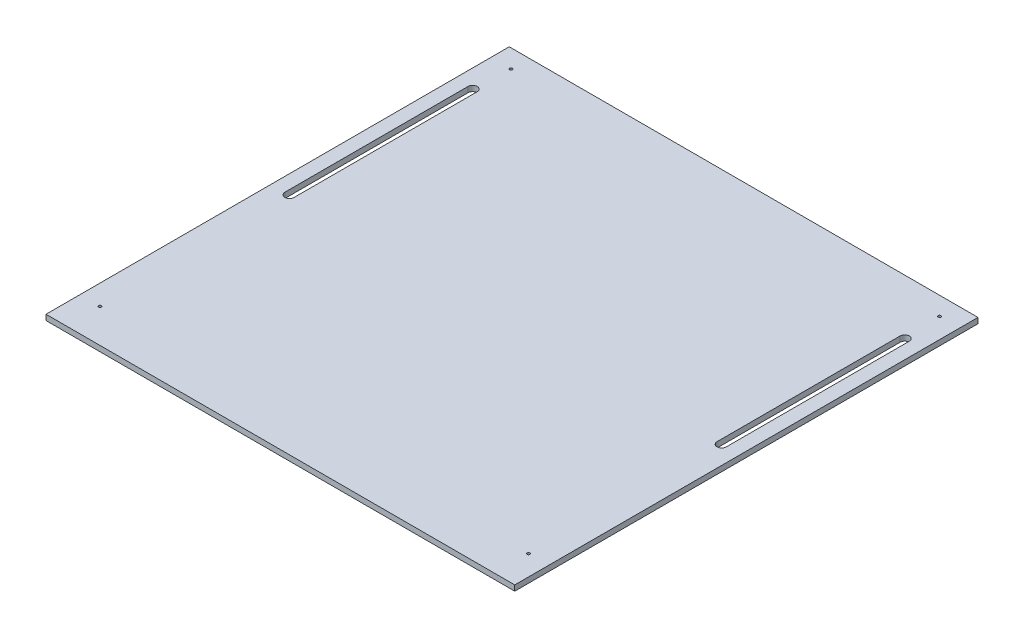
from build123d import *

# Parameters (mm, degrees)
SKETCH1_W           = 500
SKETCH1_H           = 500
SKETCH1_R           = 1.525
SKETCH1_R_2         = 1.5
BOSS_EXTRUDE1_DEPTH = 6
BOSS_EXTRUDE2_DEPTH = 6
CUT_EXTRUDE1_DEPTH  = 7


with BuildPart() as part:
    # Sketch1 → Boss-Extrude1 (new body)
    with BuildSketch(Plane(origin=(0, 0, 0), x_dir=(1, 0, 0), z_dir=(0, 1, 0))):
        with Locations((250, -250)):
            Rectangle(SKETCH1_W, SKETCH1_H)
        with Locations((484, -20)):
            Circle(SKETCH1_R, mode=Mode.SUBTRACT)
        with Locations((16, -20)):
            Circle(SKETCH1_R_2, mode=Mode.SUBTRACT)
        with Locations((484, -469)):
            Circle(SKETCH1_R_2, mode=Mode.SUBTRACT)
        with Locations((16, -469)):
            Circle(SKETCH1_R_2, mode=Mode.SUBTRACT)
    extrude(amount=BOSS_EXTRUDE1_DEPTH)

    # Sketch2 → Boss-Extrude2 (add)
    with BuildSketch(Plane.XZ):
        Polygon((-6, 506), (-6, 0), (0, 0), (0, 500), (500, 500), (500, 0), (506, 0), (506, 506), align=None)
    extrude(amount=-BOSS_EXTRUDE2_DEPTH)

    # Sketch3 → Cut-Extrude1 (cut, through all)
    with BuildSketch(Plane.XZ):
        with BuildLine():
            Line((9, 60), (9, 260))
            ThreePointArc((9, 260), (14, 265), (19, 260))
            Line((19, 260), (19, 60))
            ThreePointArc((19, 60), (14, 55), (9, 60))
        make_face()
        with BuildLine():
            Line((491, 60), (491, 260))
            ThreePointArc((491, 260), (486, 265), (481, 260))
            Line((481, 260), (481, 60))
            ThreePointArc((481, 60), (486, 55), (491, 60))
        make_face()
    extrude(amount=-CUT_EXTRUDE1_DEPTH, mode=Mode.SUBTRACT)


solid = part.part
